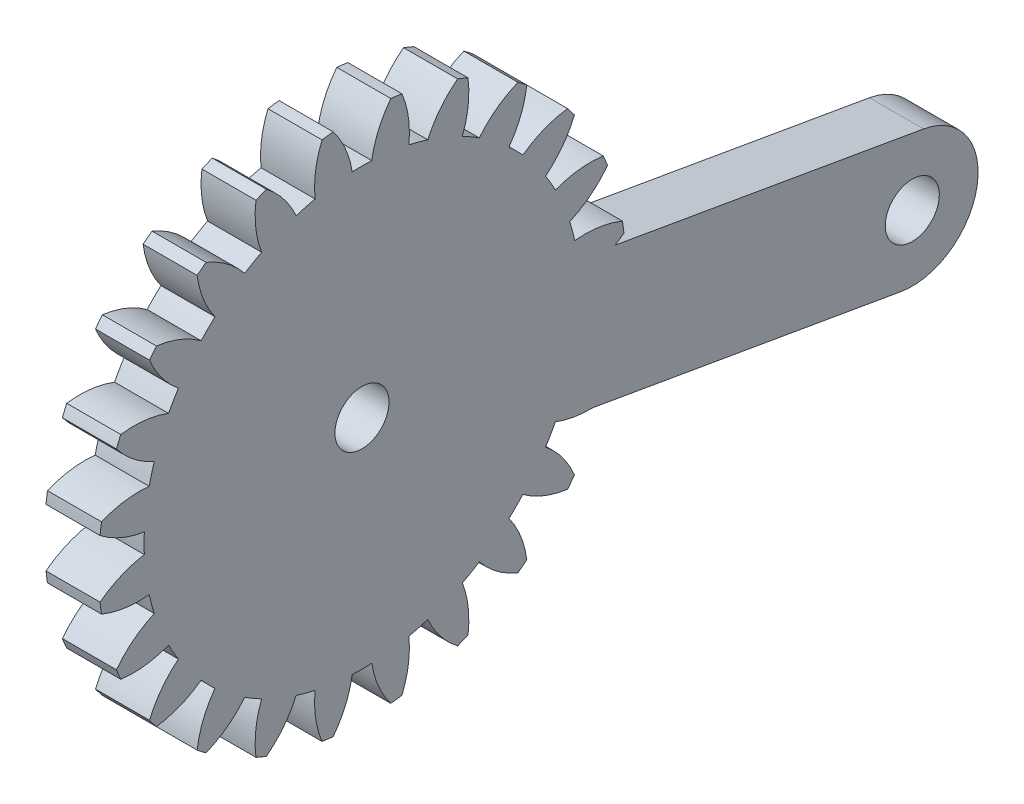
from build123d import *

# Parameters (mm, degrees)
BASPROSKE_W         = 3
BASPROSKE_H         = 14.625
TOOTHCUT_DEPTH      = 21.89931219
TEETHCUTS_COUNT     = 24
TEETHCUTS_ANGLE     = 345
BORSKE_R            = 1.5
BORE_DEPTH          = 50.0000508
SKETCH1_R           = 1.5
BOSS_EXTRUDE1_DEPTH = 3


with BuildPart() as part:
    # BasProSke → Base-Revolve (revolve)
    with BuildSketch(Plane(origin=(0, 0, 0), x_dir=(1, 0, 0), z_dir=(0, 1, 0)), mode=Mode.PRIVATE) as base_revolve_sk:
        with Locations((1.5, 7.3125)):
            Rectangle(BASPROSKE_W, BASPROSKE_H)
    revolve(base_revolve_sk.sketch.rotate(Axis((-10, 0, 0), (1, 0, 0)), 180), axis=Axis((-10, 0, 0), (1, 0, 0)))

    # TooCutSke → ToothCut (cut, through all)
    with BuildSketch(Plane(origin=(0, 0, 0), x_dir=(0, 0, -1), z_dir=(1, 0, 0))):
        with BuildLine():
            ThreePointArc((0.542722358, 12.080565177), (0, 12.09275), (-0.542722358, 12.080565177))
            ThreePointArc((-0.542722358, 12.080565177), (-0.922320579, 13.38903626), (-1.617327261, 14.56085412))
            ThreePointArc((-1.617327261, 14.56085412), (0, 14.6504), (1.617327261, 14.56085412))
            ThreePointArc((1.617327261, 14.56085412), (0.922320579, 13.38903626), (0.542722358, 12.080565177))
        make_face()
    toothcut = extrude(amount=TOOTHCUT_DEPTH, mode=Mode.SUBTRACT)

    # TeethCuts: ToothCut ×24 about axis
    teethcuts_axis = Axis((-10, 0, 0), (1, 0, 0))
    for i in range(1, TEETHCUTS_COUNT):
        add(toothcut.rotate(teethcuts_axis, i * TEETHCUTS_ANGLE / (TEETHCUTS_COUNT - 1)), mode=Mode.SUBTRACT)

    # BorSke → Bore (cut, symmetric)
    with BuildSketch(Plane(origin=(0, 0, 0), x_dir=(0, 0, -1), z_dir=(1, 0, 0))):
        with Locations(Location((0, 0, 0), (0, 0, 180))):
            Circle(BORSKE_R)
    extrude(amount=BORE_DEPTH, both=True, mode=Mode.SUBTRACT)

    # Sketch1 → Boss-Extrude1 (add)
    with BuildSketch(Plane(origin=(0, 0, 0), x_dir=(0, 0, -1), z_dir=(1, 0, 0))):
        with BuildLine():
            Line((31.167426359, -1.708998873), (11.983233878, 1.623794441))
            Line((11.983233878, 1.623794441), (10.733437515, -5.57027124))
            Line((10.733437515, -5.57027124), (29.917629996, -8.903064553))
            ThreePointArc((29.917629996, -8.903064553), (34.139561018, -5.930929895), (31.167426359, -1.708998873))
        make_face()
        with Locations((30.542528177, -5.306031713)):
            Circle(SKETCH1_R, mode=Mode.SUBTRACT)
    extrude(amount=BOSS_EXTRUDE1_DEPTH)


solid = part.part
